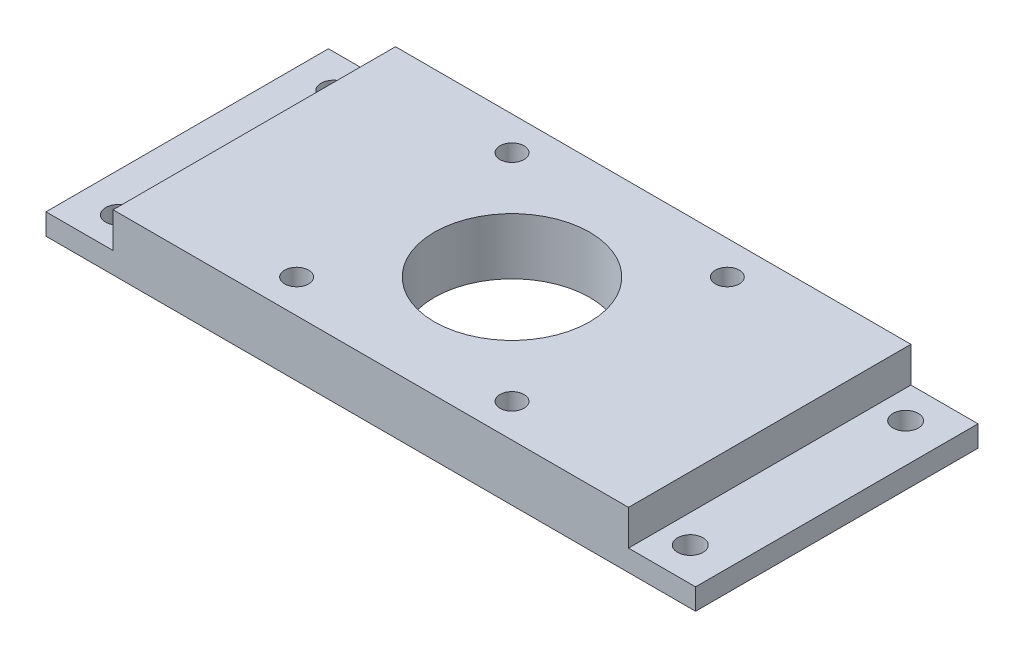
from build123d import *

# Parameters (mm, degrees)
SKETCH1_W            = 73
SKETCH1_H            = 40
BOSS_EXTRUDE1_DEPTH  = 5
SKETCH2_W            = 92
SKETCH2_H            = 40
BOSS_EXTRUDE2_DEPTH  = 3
M3_CLEARANCE_HOLE1_D = 3.6
M3_CLEARANCE_HOLE2_D = 3.4
SKETCH9_R            = 11
CUT_EXTRUDE1_DEPTH   = 9


with BuildPart() as part:
    # Sketch1 → Boss-Extrude1 (new body)
    with BuildSketch(Plane(origin=(0, 0, 0), x_dir=(1, 0, 0), z_dir=(0, 1, 0))):
        Rectangle(SKETCH1_W, SKETCH1_H)
    extrude(amount=BOSS_EXTRUDE1_DEPTH)

    # Sketch2 → Boss-Extrude2 (add)
    with BuildSketch(Plane.XZ):
        Rectangle(SKETCH2_W, SKETCH2_H)
    extrude(amount=BOSS_EXTRUDE2_DEPTH)

    # M3 Clearance Hole1 (through all)
    with Locations(Plane(origin=(0, 0, 0), x_dir=(1, 0, 0), z_dir=(0, 1, 0))):
        with Locations((-40.5, 15.25), (-40.5, -15.25), (40.5, 15.25), (40.5, -15.25)):
            Hole(M3_CLEARANCE_HOLE1_D / 2)

    # M3 Clearance Hole2 (through all)
    with Locations(Plane(origin=(0, 5, 0), x_dir=(1, 0, 0), z_dir=(0, 1, 0))):
        with Locations((0, 0), (15.25, 15.25), (-15.25, -15.25), (-15.25, 15.25), (15.25, -15.25)):
            Hole(M3_CLEARANCE_HOLE2_D / 2)

    # Sketch9 → Cut-Extrude1 (cut, through all)
    with BuildSketch(Plane(origin=(0, 5, 0), x_dir=(1, 0, 0), z_dir=(0, 1, 0))):
        Circle(SKETCH9_R)
    extrude(amount=-CUT_EXTRUDE1_DEPTH, mode=Mode.SUBTRACT)


solid = part.part
